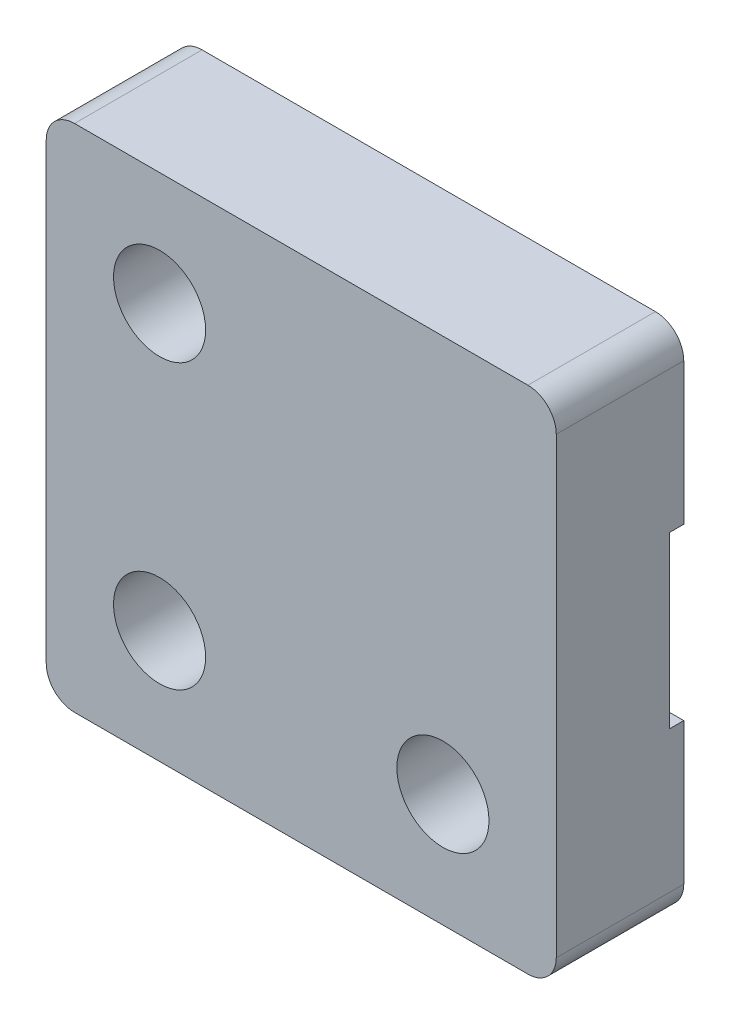
from build123d import *

# Parameters (mm, degrees)
SKETCH1_W           = 18
SKETCH1_H           = 18
SKETCH1_R           = 1.625
BOSS_EXTRUDE1_DEPTH = 4
SKETCH2_W           = 1
SKETCH2_H           = 6
CUT_EXTRUDE1_DEPTH  = 0.95
SKETCH3_R           = 1.625
BOSS_EXTRUDE2_DEPTH = 0.5
FILLET1_R           = 1


with BuildPart() as part:
    # Sketch1 → Boss-Extrude1 (new body)
    with BuildSketch(Plane.XY):
        with Locations((9, 9)):
            Rectangle(SKETCH1_W, SKETCH1_H)
        with Locations((4, 4)):
            Circle(SKETCH1_R, mode=Mode.SUBTRACT)
        with Locations((14, 4)):
            Circle(SKETCH1_R, mode=Mode.SUBTRACT)
        with Locations((14, 14)):
            Circle(SKETCH1_R, mode=Mode.SUBTRACT)
    extrude(amount=BOSS_EXTRUDE1_DEPTH)

    # Sketch2 → Cut-Extrude1 (cut)
    with BuildSketch(Plane(origin=(0, 0, 0), x_dir=(-1, 0, 0), z_dir=(0, 0, -1))):
        with Locations((-17.5, 9)):
            Rectangle(SKETCH2_W, SKETCH2_H)
        with Locations((-15.5, 9)):
            Rectangle(SKETCH2_W, SKETCH2_H)
        with Locations((-13.5, 9)):
            Rectangle(SKETCH2_W, SKETCH2_H)
        with Locations((-11.5, 9)):
            Rectangle(SKETCH2_W, SKETCH2_H)
        with Locations((-9.5, 9)):
            Rectangle(SKETCH2_W, SKETCH2_H)
        with Locations((-7.5, 9)):
            Rectangle(SKETCH2_W, SKETCH2_H)
        with Locations((-5.5, 9)):
            Rectangle(SKETCH2_W, SKETCH2_H)
        with Locations((-3.5, 9)):
            Rectangle(SKETCH2_W, SKETCH2_H)
        with Locations((-1.5, 9)):
            Rectangle(SKETCH2_W, SKETCH2_H)
    extrude(amount=-CUT_EXTRUDE1_DEPTH, mode=Mode.SUBTRACT)

    # Sketch3 → Boss-Extrude2 (add)
    with BuildSketch(Plane(origin=(0, 0, 0), x_dir=(-1, 0, 0), z_dir=(0, 0, -1))):
        Polygon((0, 0), (0, 6), (-1, 6), (-2, 6), (-3, 6), (-4, 6), (-5, 6), (-6, 6), (-7, 6), (-8, 6), (-9, 6), (-10, 6), (-11, 6), (-12, 6), (-13, 6), (-14, 6), (-15, 6), (-16, 6), (-17, 6), (-18, 6), (-18, 0), align=None)
        with Locations((-14, 4)):
            Circle(SKETCH3_R, mode=Mode.SUBTRACT)
        with Locations((-4, 4)):
            Circle(SKETCH3_R, mode=Mode.SUBTRACT)
        Polygon((0, 18), (-18, 18), (-18, 12), (-17, 12), (-16, 12), (-15, 12), (-14, 12), (-13, 12), (-12, 12), (-11, 12), (-10, 12), (-9, 12), (-8, 12), (-7, 12), (-6, 12), (-5, 12), (-4, 12), (-3, 12), (-2, 12), (-1, 12), (0, 12), align=None)
        with Locations((-14, 14)):
            Circle(SKETCH3_R, mode=Mode.SUBTRACT)
    extrude(amount=BOSS_EXTRUDE2_DEPTH)

    # Fillet1
    fillet1_edges = [part.edges().sort_by_distance(p)[0] for p in [
        (0, 18, 1.75),
        (18, 18, 1.75),
        (18, 0, 1.75),
        (0, 0, 1.75),
    ]]
    fillet(fillet1_edges, radius=FILLET1_R)


with BuildPart() as body_2:
    # Mirror1: mirrored copy
    add(part.part.mirror(Plane(origin=(18, 0, 4), x_dir=(0, 0, 1), z_dir=(-1, 0, 0))))


solid = body_2.part
